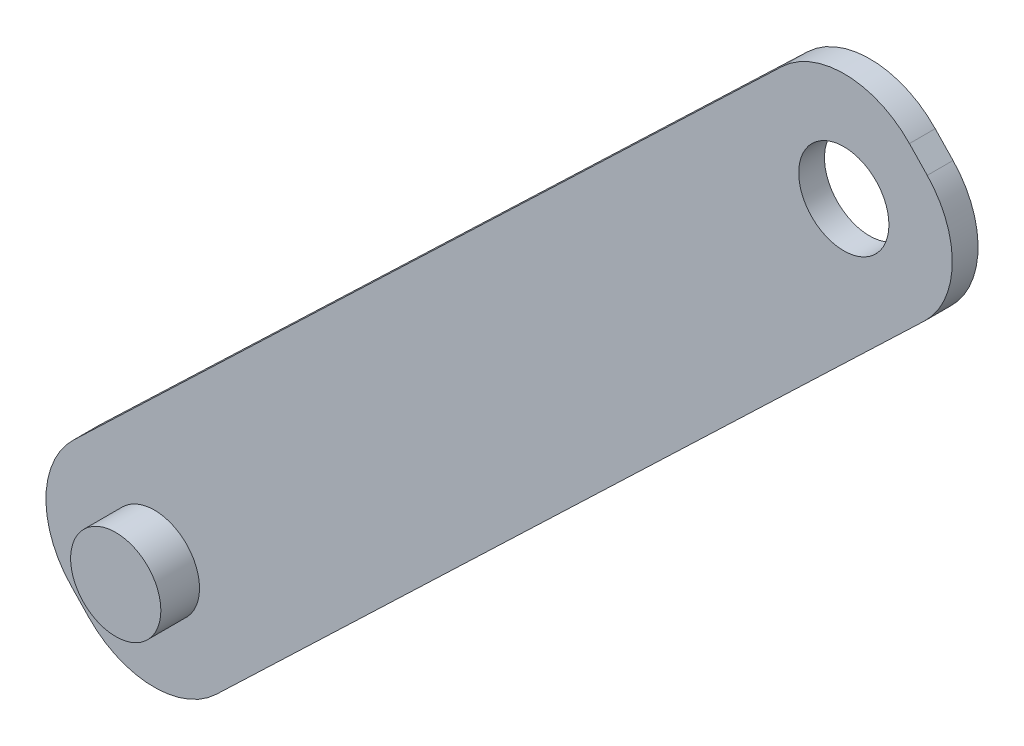
from build123d import *

# Parameters (mm, degrees)
SKETCH1_R           = 3.5
BOSS_EXTRUDE2_DEPTH = 2
SKETCH2_R           = 3.5
BOSS_EXTRUDE3_DEPTH = 3


with BuildPart() as part:
    # Sketch1 → Boss-Extrude2 (new body)
    with BuildSketch(Plane.XY):
        with BuildLine():
            ThreePointArc((31.828129573, 31.962855422), (26.925185535, 34.12264134), (21.93108129, 32.182935631))
            Line((21.93108129, 32.182935631), (-32.990473375, -20.349176769))
            ThreePointArc((-32.990473375, -20.349176769), (-35.150259292, -25.252120806), (-33.210553583, -30.246225051))
            Line((-33.210553583, -30.246225051), (-31.828129573, -31.691529121))
            ThreePointArc((-31.828129573, -31.691529121), (-26.925185535, -33.851315038), (-21.93108129, -31.91160933))
            Line((-21.93108129, -31.91160933), (32.990473375, 20.62050307))
            ThreePointArc((32.990473375, 20.62050307), (35.150259292, 25.523447107), (33.210553583, 30.517551352))
            Line((33.210553583, 30.517551352), (31.828129573, 31.962855422))
        make_face()
        with Locations((26.738125297, 25.710507345)):
            Circle(SKETCH1_R, mode=Mode.SUBTRACT)
    extrude(amount=BOSS_EXTRUDE2_DEPTH)

    # Sketch2 → Boss-Extrude3 (add)
    with BuildSketch(Plane.XY.offset(2)):
        with Locations((-26.738125297, -25.439181044)):
            Circle(SKETCH2_R)
    extrude(amount=BOSS_EXTRUDE3_DEPTH)


solid = part.part
